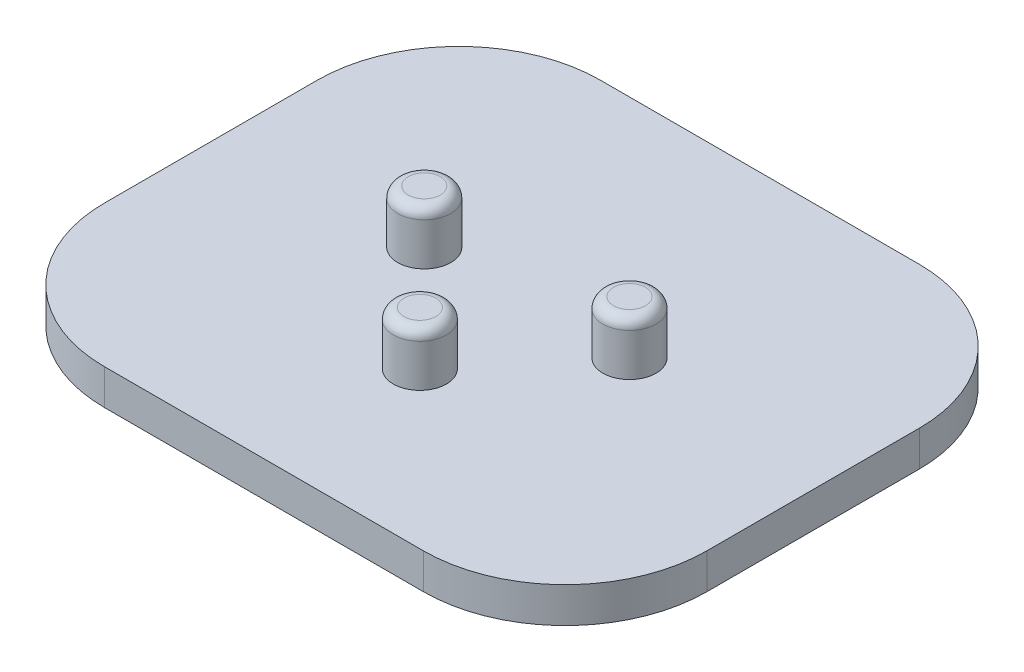
from build123d import *

# Parameters (mm, degrees)
SKETCH1_W           = 85
SKETCH1_H           = 70
BOSS_EXTRUDE1_DEPTH = 5
BOSS_EXTRUDE2_DEPTH = 7.5
FILLET1_R           = 1.5
FILLET2_R           = 20


with BuildPart() as part:
    # Sketch1 → Boss-Extrude1 (new body)
    with BuildSketch(Plane(origin=(0, 0, 0), x_dir=(1, 0, 0), z_dir=(0, 1, 0))):
        with Locations((42.5, -35)):
            Rectangle(SKETCH1_W, SKETCH1_H)
    extrude(amount=BOSS_EXTRUDE1_DEPTH)

    # Sketch2 → Boss-Extrude2 (add)
    with BuildSketch(Plane(origin=(0, 5, 0), x_dir=(1, 0, 0), z_dir=(0, 1, 0))):
        with BuildLine():
            ThreePointArc((31.712705589, -32.714866344), (24.490905169, -31.43108309), (30.560453247, -35.549709909))
            Line((30.560453247, -35.549709909), (27.964899606, -32.843125107))
            Line((27.964899606, -32.843125107), (31.712705589, -32.714866344))
        make_face()
        with BuildLine():
            Line((27.964899606, -32.843125107), (30.560453247, -35.549709909))
            ThreePointArc((30.560453247, -35.549709909), (31.41423477, -34.314378627), (31.714899606, -32.843125107))
            ThreePointArc((31.714899606, -32.843125107), (31.714351061, -32.778986344), (31.712705589, -32.714866344))
            Line((31.712705589, -32.714866344), (27.964899606, -32.843125107))
        make_face()
        with BuildLine():
            ThreePointArc((52.217093622, -32.013157813), (52.595566686, -33.531135874), (53.560453247, -34.762595649))
            Line((53.560453247, -34.762595649), (55.964899606, -31.884899051))
            Line((55.964899606, -31.884899051), (52.217093622, -32.013157813))
        make_face()
        with BuildLine():
            Line((55.964899606, -31.884899051), (53.560453247, -34.762595649))
            ThreePointArc((53.560453247, -34.762595649), (57.553267661, -35.281895801), (59.714899606, -31.884899051))
            ThreePointArc((59.714899606, -31.884899051), (55.900760842, -28.135447595), (52.217093622, -32.013157813))
            Line((52.217093622, -32.013157813), (55.964899606, -31.884899051))
        make_face()
        with BuildLine():
            Line((42.5, -48), (42.5, -51.75))
            ThreePointArc((42.5, -51.75), (45.151650429, -50.651650429), (46.25, -48))
            ThreePointArc((46.25, -48), (45.89699675, -46.411631945), (44.904446358, -45.122303402))
            Line((44.904446358, -45.122303402), (42.5, -48))
        make_face()
        with BuildLine():
            ThreePointArc((39.904446358, -45.293415198), (39.020618373, -49.398714944), (42.5, -51.75))
            Line((42.5, -51.75), (42.5, -48))
            Line((42.5, -48), (39.904446358, -45.293415198))
        make_face()
        with BuildLine():
            Line((39.904446358, -45.293415198), (42.5, -48))
            Line((42.5, -48), (44.904446358, -45.122303402))
            ThreePointArc((44.904446358, -45.122303402), (42.371741238, -44.252194017), (39.904446358, -45.293415198))
        make_face()
    extrude(amount=BOSS_EXTRUDE2_DEPTH)

    # Fillet1
    fillet1_edges = [part.edges().sort_by_distance(p)[0] for p in [
        (25.369345964, 12.5, 30.136540305),
        (59.712705589, 12.5, 31.756640288),
        (45.095553642, 12.5, 50.706584802),
    ]]
    fillet(fillet1_edges, radius=FILLET1_R)

    # Fillet2
    fillet2_edges = [part.edges().sort_by_distance(p)[0] for p in [
        (0, 2.5, 0),
        (85, 2.5, 0),
        (85, 2.5, 70),
        (0, 2.5, 70),
    ]]
    fillet(fillet2_edges, radius=FILLET2_R)


solid = part.part
